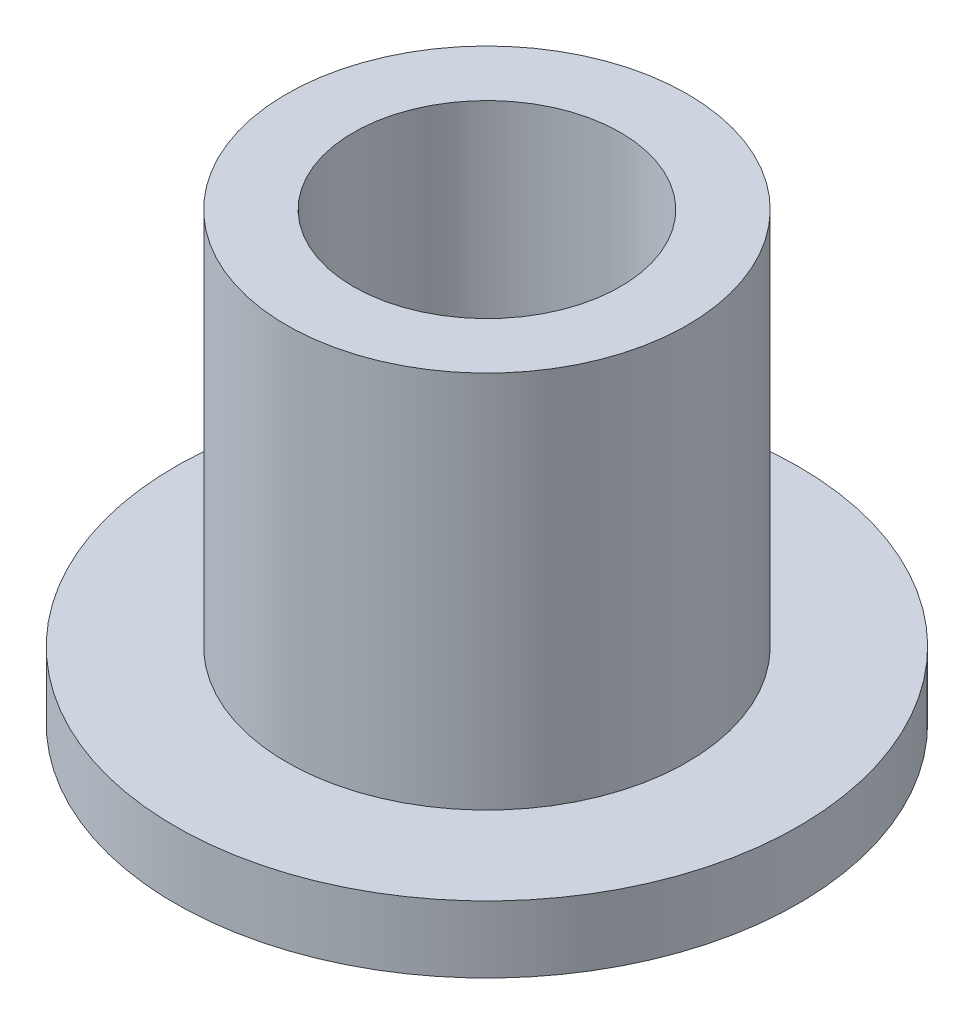
from build123d import *


with BuildPart() as part:
    # ｽｹｯﾁ1 → 回転1 (revolve)
    with BuildSketch(Plane.XY):
        Polygon((1.5, 0), (3.5, 0), (3.5, 0.75), (2.25, 0.75), (2.25, 5), (1.5, 5), align=None)
    revolve(axis=Axis((0, 0, 0), (0, 1, 0)))


solid = part.part
